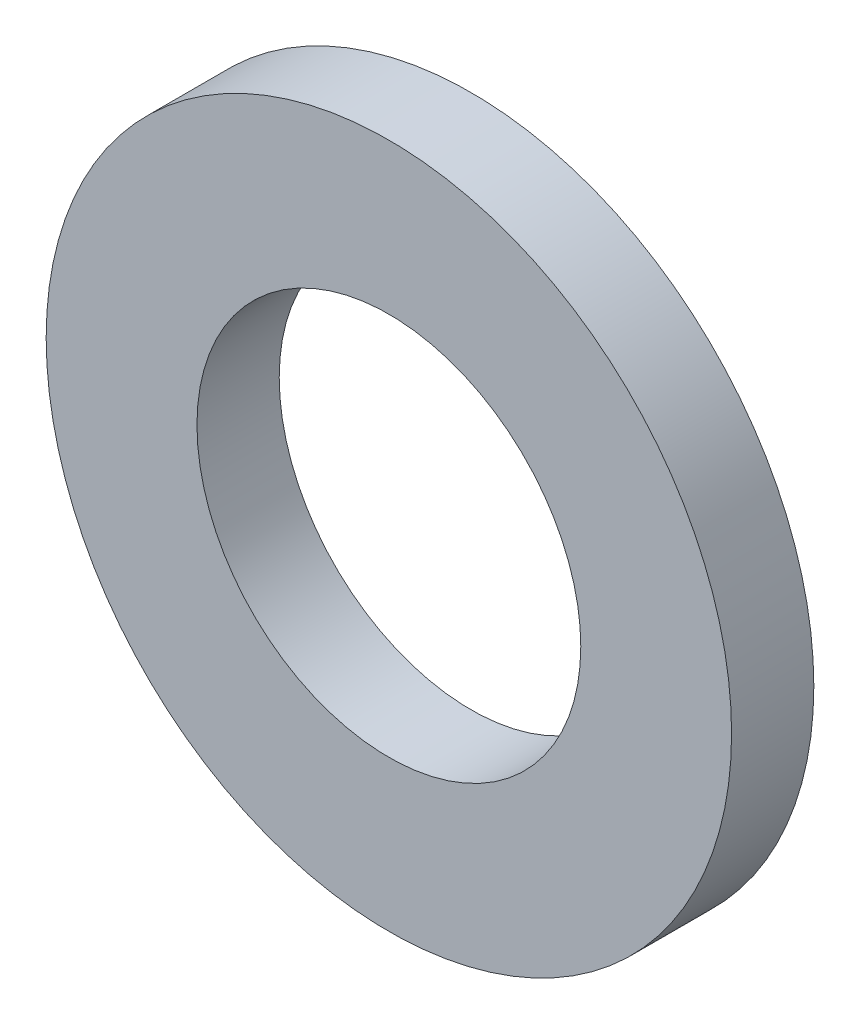
from build123d import *

# Parameters (mm, degrees)
SKETCH1_R           = 7.5
SKETCH1_R_2         = 4.2
BOSS_EXTRUDE1_DEPTH = 1.8


with BuildPart() as part:
    # Sketch1 → Boss-Extrude1 (new body)
    with BuildSketch(Plane.XY):
        Circle(SKETCH1_R)
        Circle(SKETCH1_R_2, mode=Mode.SUBTRACT)
    extrude(amount=BOSS_EXTRUDE1_DEPTH)


solid = part.part
